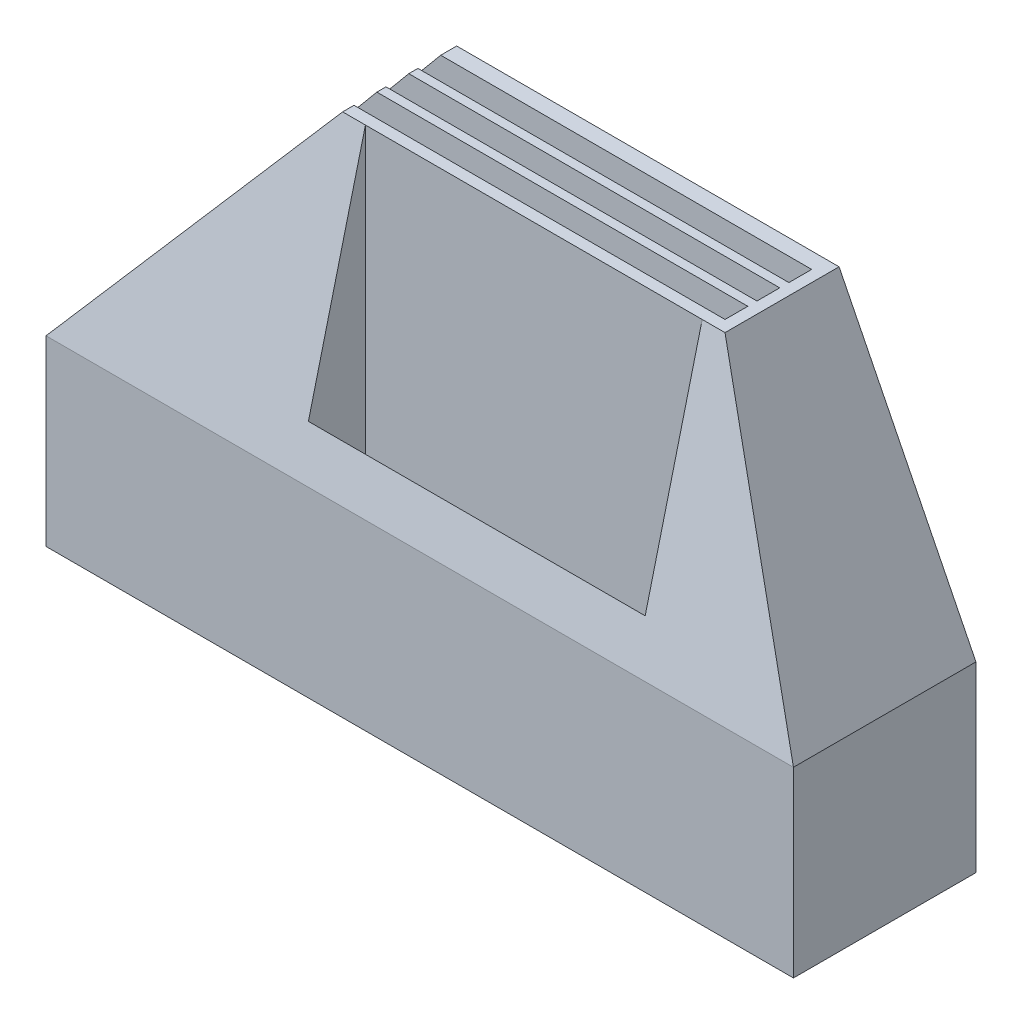
from build123d import *

# Parameters (mm, degrees)
SKETCH1_W           = 416.08
SKETCH1_H           = 101.6
BOSS_EXTRUDE2_DEPTH = 254
CUT_EXTRUDE1_DEPTH  = 101.6
CUT_EXTRUDE9_START  = 10.16
SKETCH6_W           = 187.48
SKETCH6_H           = 31.75
CUT_EXTRUDE9_DEPTH  = 244.84
SKETCH8_W           = 327.18
SKETCH8_H           = 12.7
CUT_EXTRUDE11_DEPTH = 228.6
CUT_EXTRUDE12_DEPTH = 417.08
CUT_EXTRUDE13_REACH = 65.5
SKETCH10_W          = 162.08
SKETCH10_H          = 13.204649201


with BuildPart() as part:
    # Sketch1 → Boss-Extrude2 (new body)
    with BuildSketch(Plane(origin=(0, 0, 0), x_dir=(1, 0, 0), z_dir=(0, 1, 0))):
        with Locations((208.04, 50.8)):
            Rectangle(SKETCH1_W, SKETCH1_H)
    extrude(amount=BOSS_EXTRUDE2_DEPTH)

    # Sketch2 → Cut-Extrude1 (cut)
    with BuildSketch(Plane.XY):
        Polygon((0, 101.6), (0, 254), (127, 254), align=None)
        Polygon((416.08, 254), (416.08, 101.6), (339.88, 254), align=None)
    extrude(amount=-CUT_EXTRUDE1_DEPTH, mode=Mode.SUBTRACT)

    # Sketch6 → Cut-Extrude9 (cut, through all)
    with BuildSketch(Plane(origin=(0, 0, 0), x_dir=(1, 0, 0), z_dir=(0, 1, 0)).offset(CUT_EXTRUDE9_START)):
        with Locations((233.44, 22.225)):
            Rectangle(SKETCH6_W, SKETCH6_H)
    extrude(amount=CUT_EXTRUDE9_DEPTH, mode=Mode.SUBTRACT)

    # Sketch8 → Cut-Extrude11 (cut)
    with BuildSketch(Plane(origin=(0, 254, 0), x_dir=(1, 0, 0), z_dir=(0, 1, 0))):
        with Locations((169.94, 50.8)):
            Rectangle(SKETCH8_W, SKETCH8_H)
        with Locations((169.94, 68.58)):
            Rectangle(SKETCH8_W, SKETCH8_H)
        with Locations((169.94, 86.36)):
            Rectangle(SKETCH8_W, SKETCH8_H)
    extrude(amount=-CUT_EXTRUDE11_DEPTH, mode=Mode.SUBTRACT)

    # Sketch9 → Cut-Extrude12 (cut, through all)
    with BuildSketch(Plane(origin=(416.08, 0, 0), x_dir=(0, 0, -1), z_dir=(1, 0, 0))):
        Polygon((0, 254), (0, 101.6), (38.1, 254), align=None)
    extrude(amount=-CUT_EXTRUDE12_DEPTH, mode=Mode.SUBTRACT)

    # Sketch10 → Cut-Extrude13 (cut, up to next)
    with BuildSketch(Plane.XY.offset(-38.1), mode=Mode.PRIVATE) as cut_extrude13_sk1:
        with Locations((233.44, 17.056383054)):
            Rectangle(SKETCH10_W, SKETCH10_H)
    cut_extrude13_tool1 = extrude(cut_extrude13_sk1.sketch, amount=-CUT_EXTRUDE13_REACH, mode=Mode.PRIVATE) & part.part
    add(cut_extrude13_tool1.solids().sort_by_distance((233.44, 17.056383, -38.1))[0], mode=Mode.SUBTRACT)


solid = part.part
